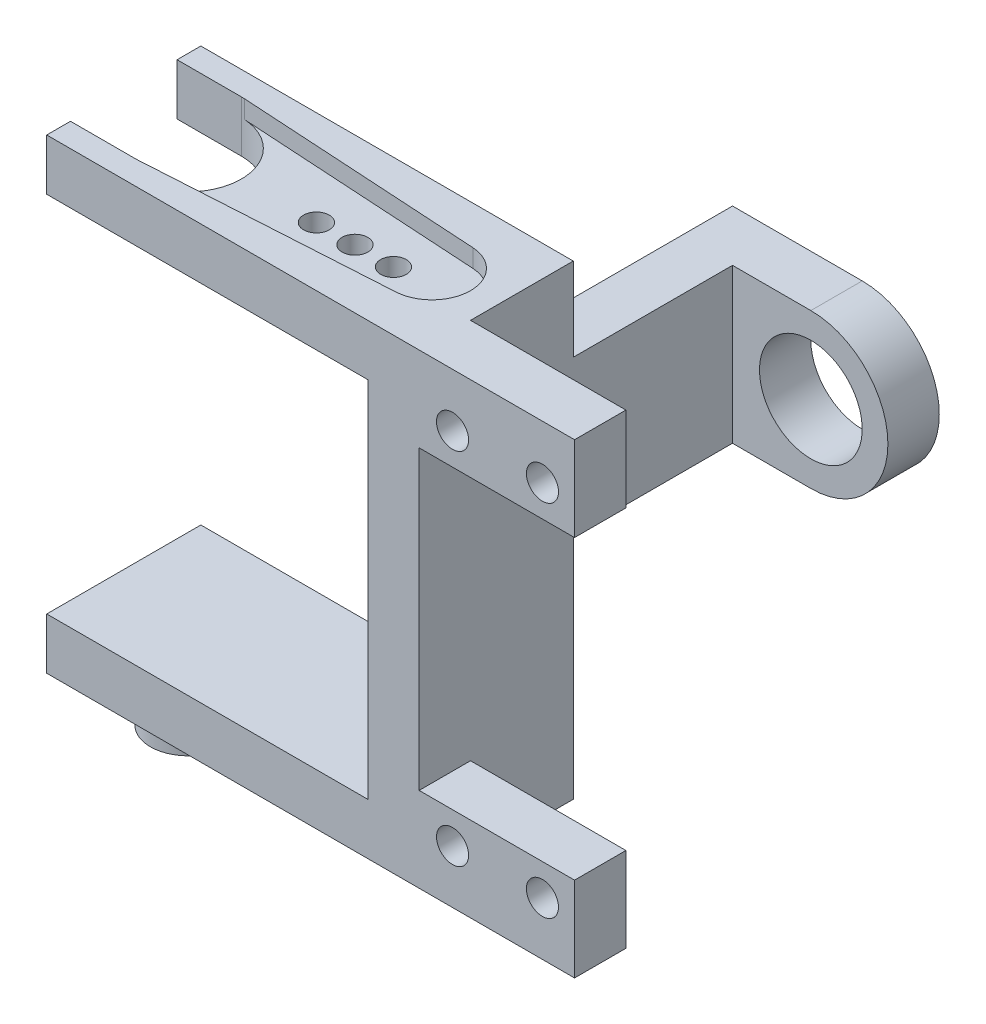
from build123d import *

# Parameters (mm, degrees)
EXTRUDE_1_DEPTH     = 12
SKETCH_2_R          = 2.925
EXTRUDE_2_DEPTH     = 4
SKETCH_3_W          = 12.1
SKETCH_3_H          = 6.6
SKETCH_3_R          = 1.25
EXTRUDE_3_DEPTH     = 4
SKETCH_4_W          = 12.4
SKETCH_4_H          = 12
EXTRUDE_4_DEPTH     = 4
EXTRUDE_5_DEPTH     = 4
SKETCH_6_R          = 4
CUT_EXTRUDE_1_DEPTH = 4
CUT_EXTRUDE_2_DEPTH = 4
SKETCH_8_R          = 1
CUT_EXTRUDE_3_DEPTH = 1.4
SKETCH_8_3_R        = 1
CUT_EXTRUDE_4_DEPTH = 4
SKETCH_9_R          = 1.5
CUT_EXTRUDE_5_DEPTH = 5


with BuildPart() as part:
    # 草图1 → 凸台-拉伸1 (new body)
    with BuildSketch(Plane.XY):
        Polygon((0, 0), (25, 0), (25, 28.3), (0, 28.3), (0, 32.3), (29, 32.3), (29, -4), (0, -4), align=None)
    extrude(amount=EXTRUDE_1_DEPTH)

    # 草图2 → 凸台-拉伸2 (add)
    with BuildSketch(Plane.XZ.offset(4)):
        with Locations((5, 6)):
            Circle(SKETCH_2_R)
    extrude(amount=EXTRUDE_2_DEPTH)

    # 草图3 → 凸台-拉伸3 (add)
    # profile 1 of 2: a face of its own
    with BuildSketch(Plane.XY.offset(12)):
        with Locations((35.05, 29)):
            Rectangle(SKETCH_3_W, SKETCH_3_H)
        with Locations((31.6, 28.15)):
            Circle(SKETCH_3_R, mode=Mode.SUBTRACT)
        with Locations((38.6, 28.15)):
            Circle(SKETCH_3_R, mode=Mode.SUBTRACT)
    # profile 2 of 2: a face of its own
    with BuildSketch(Plane.XY.offset(12)):
        with Locations((35.05, -0.7)):
            Rectangle(SKETCH_3_W, SKETCH_3_H)
        with Locations((38.6, 0.15)):
            Circle(SKETCH_3_R, mode=Mode.SUBTRACT)
        with Locations((31.6, 0.15)):
            Circle(SKETCH_3_R, mode=Mode.SUBTRACT)
    extrude(amount=-EXTRUDE_3_DEPTH)

    # 草图4 → 凸台-拉伸4 (add)
    with BuildSketch(Plane(origin=(29, 0, 0), x_dir=(0, 0, -1), z_dir=(1, 0, 0))):
        with Locations((6.2, 19.81)):
            Rectangle(SKETCH_4_W, SKETCH_4_H)
    extrude(amount=-EXTRUDE_4_DEPTH)

    # 草图5 → 凸台-拉伸5 (add)
    with BuildSketch(Plane(origin=(0, 0, -12.4), x_dir=(-1, 0, 0), z_dir=(0, 0, -1))):
        with BuildLine():
            Line((-35.1, 13.81), (-25, 13.81))
            Line((-25, 13.81), (-25, 25.81))
            Line((-25, 25.81), (-35.1, 25.81))
            ThreePointArc((-35.1, 25.81), (-41.1, 19.81), (-35.1, 13.81))
        make_face()
    extrude(amount=EXTRUDE_5_DEPTH)

    # 草图6 → 切除-拉伸1 (cut)
    with BuildSketch(Plane(origin=(0, 0, -16.4), x_dir=(-1, 0, 0), z_dir=(0, 0, -1))):
        with Locations((-35.1, 19.81)):
            Circle(SKETCH_6_R)
    extrude(amount=-CUT_EXTRUDE_1_DEPTH, mode=Mode.SUBTRACT)

    # 草图7 → 切除-拉伸2 (cut)
    with BuildSketch(Plane(origin=(0, 32.3, 0), x_dir=(1, 0, 0), z_dir=(0, 1, 0))):
        with BuildLine():
            Line((0, -1.85), (0, -10.15))
            Line((0, -10.15), (5, -10.15))
            ThreePointArc((5, -10.15), (9.15, -6), (5, -1.85))
            Line((5, -1.85), (0, -1.85))
        make_face()
    extrude(amount=-CUT_EXTRUDE_2_DEPTH, mode=Mode.SUBTRACT)

    # 草图8 → 切除-拉伸3 (cut)
    with BuildSketch(Plane(origin=(0, 32.3, 0), x_dir=(1, 0, 0), z_dir=(0, 1, 0))):
        with BuildLine():
            ThreePointArc((5.251184211, -1.857608602), (9.15, -6), (5.251184211, -10.142391398))
            Line((5.251184211, -10.142391398), (24.181578947, -8.994499806))
            ThreePointArc((24.181578947, -8.994499806), (27, -6), (24.181578947, -3.005500194))
            Line((24.181578947, -3.005500194), (5.251184211, -1.857608602))
        make_face()
        with Locations((21, -6)):
            Circle(SKETCH_8_R, mode=Mode.SUBTRACT)
        with Locations((18, -6)):
            Circle(SKETCH_8_R, mode=Mode.SUBTRACT)
        with Locations((15, -6)):
            Circle(SKETCH_8_R, mode=Mode.SUBTRACT)
    extrude(amount=-CUT_EXTRUDE_3_DEPTH, mode=Mode.SUBTRACT)

    # 草图8<3> → 切除-拉伸4 (cut)
    with BuildSketch(Plane(origin=(0, 32.3, 0), x_dir=(1, 0, 0), z_dir=(0, 1, 0))):
        with Locations((15, -6)):
            Circle(SKETCH_8_3_R)
        with Locations((18, -6)):
            Circle(SKETCH_8_3_R)
        with Locations((21, -6)):
            Circle(SKETCH_8_3_R)
    extrude(amount=-CUT_EXTRUDE_4_DEPTH, mode=Mode.SUBTRACT)

    # 草图9 → 切除-拉伸5 (cut)
    with BuildSketch(Plane.XZ.offset(8)):
        with Locations((4.998125707, 6.006461186)):
            Circle(SKETCH_9_R)
    extrude(amount=-CUT_EXTRUDE_5_DEPTH, mode=Mode.SUBTRACT)


solid = part.part
